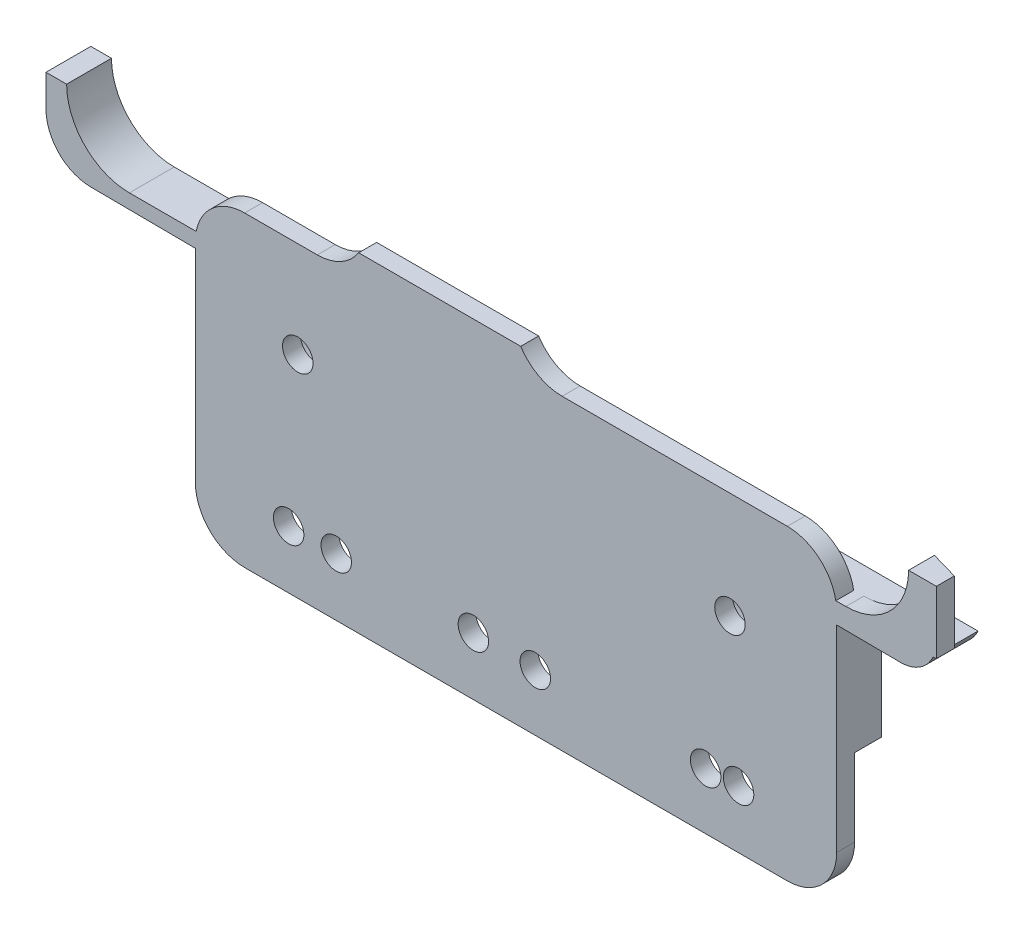
from build123d import *

# Parameters (mm, degrees)
ESQUISSE1_R             = 1.7
BOSS_EXTRU_1_DEPTH      = 3
BOSS_EXTRU_2_DEPTH      = 3
BOSS_EXTRU_2_DEPTH_BACK = 3
ESQUISSE2_R             = 5.2
ESQUISSE5_W             = 129.390100882
ESQUISSE5_H             = 125.631489025
ENL_V_MAT_EXTRU_2_DEPTH = 1
ESQUISSE6_R             = 1.5
ENL_V_MAT_EXTRU_3_DEPTH = 8
ESQUISSE7_W             = 14.610679854
ESQUISSE7_H             = 62.75
ENL_V_MAT_EXTRU_4_DEPTH = 8
BOSS_EXTRU_3_DEPTH      = 7
BOSS_EXTRU_4_DEPTH      = 7
ESQUISSE11_W            = 143.807333736
ESQUISSE11_H            = 19.954067826
ENL_V_MAT_EXTRU_5_DEPTH = 89
ESQUISSE12_R            = 1.7
ENL_V_MAT_EXTRU_6_DEPTH = 31


with BuildPart() as part:
    # Esquisse1 → Boss.-Extru.1 (new body)
    with BuildSketch(Plane.XY):
        with BuildLine():
            Line((-117.680084405, 66.939310237), (-117.680084405, 59.695120061))
            ThreePointArc((-117.680084405, 59.695120061), (-116.069171702, 55.806032765), (-112.180084405, 54.195120061))
            Line((-112.180084405, 54.195120061), (-105.294175096, 54.195120061))
            ThreePointArc((-105.294175096, 54.195120061), (-101.4050878, 52.584207358), (-99.794175096, 48.695120061))
            Line((-99.794175096, 48.695120061), (-99.794175096, 35.930823665))
            ThreePointArc((-99.794175096, 35.930823665), (-101.4050878, 32.041736368), (-105.294175096, 30.430823665))
            Line((-105.294175096, 30.430823665), (-112.180084405, 30.430823665))
            ThreePointArc((-112.180084405, 30.430823665), (-116.069171702, 28.819910961), (-117.680084405, 24.930823665))
            Line((-117.680084405, 24.930823665), (-117.680084405, 23.910007682))
            ThreePointArc((-117.680084405, 23.910007682), (-116.069171702, 20.020920385), (-112.180084405, 18.410007682))
            Line((-112.180084405, 18.410007682), (-105.294175096, 18.410007682))
            ThreePointArc((-105.294175096, 18.410007682), (-101.4050878, 16.799094979), (-99.794175096, 12.910007682))
            Line((-99.794175096, 12.910007682), (-99.794175096, 1.692208933))
            ThreePointArc((-99.794175096, 1.692208933), (-101.4050878, -2.196878364), (-105.294175096, -3.807791067))
            Line((-105.294175096, -3.807791067), (-113.390601299, -3.807791067))
            ThreePointArc((-113.390601299, -3.807791067), (-117.279688595, -5.418703771), (-118.890601299, -9.307791067))
            Line((-118.890601299, -9.307791067), (-118.890601299, -18.42196685))
            Line((-118.890601299, -18.42196685), (-118.890601299, -32.5606385))
            ThreePointArc((-118.890601299, -32.5606385), (-117.279688595, -36.449725797), (-113.390601299, -38.0606385))
            Line((-113.390601299, -38.0606385), (-52.866544484, -38.0606385))
            ThreePointArc((-52.866544484, -38.0606385), (-48.977457187, -36.449725797), (-47.366544484, -32.5606385))
            Line((-47.366544484, -32.5606385), (-47.366544484, -18.42196685))
            Line((-47.366544484, -18.42196685), (-47.366544484, -9.307791067))
            ThreePointArc((-47.366544484, -9.307791067), (-48.977457187, -5.418703771), (-52.866544484, -3.807791067))
            Line((-52.866544484, -3.807791067), (-77.986378892, -3.807791067))
            ThreePointArc((-77.986378892, -3.807791067), (-81.875466189, -2.196878364), (-83.486378892, 1.692208933))
            Line((-83.486378892, 1.692208933), (-83.486378892, 12.910007682))
            ThreePointArc((-83.486378892, 12.910007682), (-81.875466189, 16.799094979), (-77.986378892, 18.410007682))
            Line((-77.986378892, 18.410007682), (-69.856378892, 18.410007682))
            ThreePointArc((-69.856378892, 18.410007682), (-65.967291596, 20.020920385), (-64.356378892, 23.910007682))
            Line((-64.356378892, 23.910007682), (-64.356378892, 24.930823665))
            ThreePointArc((-64.356378892, 24.930823665), (-65.967291596, 28.819910961), (-69.856378892, 30.430823665))
            Line((-69.856378892, 30.430823665), (-77.986378892, 30.430823665))
            ThreePointArc((-77.986378892, 30.430823665), (-81.875466189, 32.041736368), (-83.486378892, 35.930823665))
            Line((-83.486378892, 35.930823665), (-83.486378892, 55.219310237))
            ThreePointArc((-83.486378892, 55.219310237), (-81.875466189, 59.108397534), (-77.986378892, 60.719310237))
            Line((-77.986378892, 60.719310237), (-54.190366806, 60.719310237))
            ThreePointArc((-54.190366806, 60.719310237), (-50.30127951, 62.330222941), (-48.690366806, 66.219310237))
            Line((-48.690366806, 66.219310237), (-48.690366806, 67.219310237))
            ThreePointArc((-48.690366806, 67.219310237), (-50.30127951, 71.108397534), (-54.190366806, 72.719310237))
            Line((-54.190366806, 72.719310237), (-112.180084405, 72.719310237))
            ThreePointArc((-112.180084405, 72.719310237), (-116.069171702, 71.108397534), (-117.680084405, 67.219310237))
            Line((-117.680084405, 67.219310237), (-117.680084405, 66.939310237))
        make_face()
        with Locations((-59.266378892, -15.663707737)):
            Circle(ESQUISSE1_R, mode=Mode.SUBTRACT)
        with Locations((-59.266378892, 66.939310237)):
            Circle(ESQUISSE1_R, mode=Mode.SUBTRACT)
        with Locations((-91.856378892, 36.719310237)):
            Circle(ESQUISSE1_R, mode=Mode.SUBTRACT)
        with Locations((-107.466378892, -14.520689763)):
            Circle(ESQUISSE1_R, mode=Mode.SUBTRACT)
        with Locations((-107.466378892, 60.719310237)):
            Circle(ESQUISSE1_R, mode=Mode.SUBTRACT)
        with Locations((-58.306378892, -31.603707737)):
            Circle(ESQUISSE1_R, mode=Mode.SUBTRACT)
        with Locations((-108.486378892, -31.600689763)):
            Circle(ESQUISSE1_R, mode=Mode.SUBTRACT)
        with BuildLine():
            Line((-111.390601299, 21.460065469), (-70.086378892, 21.460065469))
            ThreePointArc((-70.086378892, 21.460065469), (-68.67216533, 22.045851906), (-68.086378892, 23.460065469))
            Line((-68.086378892, 23.460065469), (-68.086378892, 24.842520386))
            ThreePointArc((-68.086378892, 24.842520386), (-68.67216533, 26.256733949), (-70.086378892, 26.842520386))
            Line((-70.086378892, 26.842520386), (-111.390601299, 26.842520386))
            ThreePointArc((-111.390601299, 26.842520386), (-112.804814861, 26.256733949), (-113.390601299, 24.842520386))
            Line((-113.390601299, 24.842520386), (-113.390601299, 23.460065469))
            ThreePointArc((-113.390601299, 23.460065469), (-112.804814861, 22.045851906), (-111.390601299, 21.460065469))
        make_face(mode=Mode.SUBTRACT)
    extrude(amount=BOSS_EXTRU_1_DEPTH)

    # Esquisse2 → Boss.-Extru.2 (add, two sides: drawn at the far end of the back side and taken through both)
    with BuildSketch(Plane(origin=(0, 0, 0), x_dir=(-1, 0, 0), z_dir=(0, 0, -1)).offset(-BOSS_EXTRU_2_DEPTH_BACK)):
        with BuildLine():
            Line((118.890601299, -9.969506719), (130.584615963, -9.880075131))
            ThreePointArc((130.584615963, -9.880075131), (134.095405897, -8.402210456), (135.546378892, -4.880221341))
            Line((135.546378892, -4.880221341), (135.546378892, 5.415623015))
            ThreePointArc((135.546378892, 5.415623015), (136.425058549, 7.536943358), (138.546378892, 8.415623015))
            Line((138.546378892, 8.415623015), (145.752654566, 8.415623015))
            ThreePointArc((145.752654566, 8.415623015), (147.87397491, 9.294302671), (148.752654566, 11.415623015))
            Line((148.752654566, 11.415623015), (148.752654566, 38.179170847))
            ThreePointArc((148.752654566, 38.179170847), (147.87397491, 40.300491191), (145.752654566, 41.179170847))
            Line((145.752654566, 41.179170847), (138.546378892, 41.179170847))
            ThreePointArc((138.546378892, 41.179170847), (136.425058549, 42.057850504), (135.546378892, 44.179170847))
            Line((135.546378892, 44.179170847), (135.546378892, 52.099902349))
            ThreePointArc((135.546378892, 52.099902349), (134.081912798, 55.635436255), (130.546378892, 57.099902349))
            Line((130.546378892, 57.099902349), (117.680084405, 57.099902349))
            Line((117.680084405, 57.099902349), (117.680084405, 72.719310237))
            Line((117.680084405, 72.719310237), (48.690366806, 72.719310237))
            Line((48.690366806, 72.719310237), (48.690366806, 60.719310237))
            Line((48.690366806, 60.719310237), (48.690366806, 57.099902349))
            Line((48.690366806, 57.099902349), (40.256901013, 57.099902349))
            ThreePointArc((40.256901013, 57.099902349), (37.428473888, 55.928329474), (36.256901013, 53.099902349))
            Line((36.256901013, 53.099902349), (36.256901013, 47.456292263))
            Line((36.256901013, 47.456292263), (39.346378892, 47.456292263))
            ThreePointArc((39.346378892, 47.456292263), (41.396631424, 52.406039732), (46.346378892, 54.456292263))
            Line((46.346378892, 54.456292263), (126.246378892, 54.456292263))
            ThreePointArc((126.246378892, 54.456292263), (131.196126361, 52.406039732), (133.246378892, 47.456292263))
            Line((133.246378892, 47.456292263), (133.246378892, 40.977229779))
            ThreePointArc((133.246378892, 40.977229779), (134.125058549, 38.855909436), (136.246378892, 37.977229779))
            Line((136.246378892, 37.977229779), (142.162261637, 37.977229779))
            ThreePointArc((142.162261637, 37.977229779), (144.28358198, 37.098550123), (145.162261637, 34.977229779))
            Line((145.162261637, 34.977229779), (145.162261637, 14.363062522))
            ThreePointArc((145.162261637, 14.363062522), (144.28358198, 12.241742179), (142.162261637, 11.363062522))
            Line((142.162261637, 11.363062522), (136.246378892, 11.363062522))
            ThreePointArc((136.246378892, 11.363062522), (134.125058549, 10.484382866), (133.246378892, 8.363062522))
            Line((133.246378892, 8.363062522), (133.246378892, -1.293707737))
            ThreePointArc((133.246378892, -1.293707737), (131.196126361, -6.243455205), (126.246378892, -8.293707737))
            Line((126.246378892, -8.293707737), (46.346378892, -8.293707737))
            ThreePointArc((46.346378892, -8.293707737), (41.396631424, -6.243455205), (39.346378892, -1.293707737))
            Line((39.346378892, -1.293707737), (36.248203357, -1.293707737))
            Line((36.248203357, -1.293707737), (36.248203357, -6.64542392))
            ThreePointArc((36.248203357, -6.64542392), (37.432020164, -9.486042202), (40.282759469, -10.645274652))
            Line((40.282759469, -10.645274652), (47.366544484, -10.58407535))
            Line((47.366544484, -10.58407535), (47.366544484, -23.92196685))
            Line((47.366544484, -23.92196685), (118.890601299, -23.92196685))
            Line((118.890601299, -23.92196685), (118.890601299, -9.969506719))
        make_face()
        with Locations((59.266378892, -15.663707737)):
            Circle(ESQUISSE2_R, mode=Mode.SUBTRACT)
        with Locations((107.466378892, -14.520689763)):
            Circle(ESQUISSE2_R, mode=Mode.SUBTRACT)
        with Locations((107.466378892, 60.719310237)):
            Circle(ESQUISSE2_R, mode=Mode.SUBTRACT)
        with Locations((59.266378892, 66.939310237)):
            Circle(ESQUISSE2_R, mode=Mode.SUBTRACT)
    extrude(amount=BOSS_EXTRU_2_DEPTH + BOSS_EXTRU_2_DEPTH_BACK)

    # Esquisse5 → Enlèv. mat.-Extru.2 (cut)
    with BuildSketch(Plane.XY.offset(3)):
        with Locations((-91.695706627, 17.054727605)):
            Rectangle(ESQUISSE5_W, ESQUISSE5_H)
    extrude(amount=-ENL_V_MAT_EXTRU_2_DEPTH, mode=Mode.SUBTRACT)

    # Esquisse6 → Enlèv. mat.-Extru.3 (cut)
    with BuildSketch(Plane.XY.offset(2)):
        with Locations((-69.623492164, 64.727424081)):
            Circle(ESQUISSE6_R)
        with Locations((-83.623492164, 64.727424081)):
            Circle(ESQUISSE6_R)
    extrude(amount=-ENL_V_MAT_EXTRU_3_DEPTH, mode=Mode.SUBTRACT)

    # Esquisse7 → Enlèv. mat.-Extru.4 (cut)
    with BuildSketch(Plane(origin=(0, 0, 0), x_dir=(-1, 0, 0), z_dir=(0, 0, -1))):
        with Locations((42.567758063, 23.081292263)):
            Rectangle(ESQUISSE7_W, ESQUISSE7_H)
    extrude(amount=ENL_V_MAT_EXTRU_4_DEPTH, mode=Mode.SUBTRACT)

    # Esquisse9 → Boss.-Extru.3 (add)
    with BuildSketch(Plane(origin=(0, -1.293707737, 0), x_dir=(1, 0, 0), z_dir=(0, 1, 0))):
        Polygon((-39.346378892, -2), (-39.346378892, 0.886005049), (-36.248203357, 0), (-36.248203357, -2), align=None)
    extrude(amount=-BOSS_EXTRU_3_DEPTH)

    # Esquisse10 → Boss.-Extru.4 (add)
    with BuildSketch(Plane.XZ.offset(-47.456292263)):
        Polygon((-39.346378892, 2), (-39.346378892, -0.873043126), (-36.256901013, 0), (-36.256901013, 2), align=None)
    extrude(amount=-BOSS_EXTRU_4_DEPTH)

    # Esquisse11 → Enlèv. mat.-Extru.5 (cut)
    with BuildSketch(Plane(origin=(0, -1.293707737, 0), x_dir=(1, 0, 0), z_dir=(0, 1, 0))):
        with Locations((-95.995427174, 3.905261548)):
            Rectangle(ESQUISSE11_W, ESQUISSE11_H)
    extrude(amount=ENL_V_MAT_EXTRU_5_DEPTH, mode=Mode.SUBTRACT)

    # Esquisse12 → Enlèv. mat.-Extru.6 (cut)
    with BuildSketch(Plane.XY.offset(2)):
        with Locations((-103.175863959, -31.601009153)):
            Circle(ESQUISSE12_R)
        with Locations((-87.885863987, -31.601928739)):
            Circle(ESQUISSE12_R)
        with Locations((-80.977833602, -31.748759482)):
            Circle(ESQUISSE12_R)
        with Locations((-61.977833602, -31.748759482)):
            Circle(ESQUISSE12_R)
    extrude(amount=-ENL_V_MAT_EXTRU_6_DEPTH, mode=Mode.SUBTRACT)


solid = part.part
